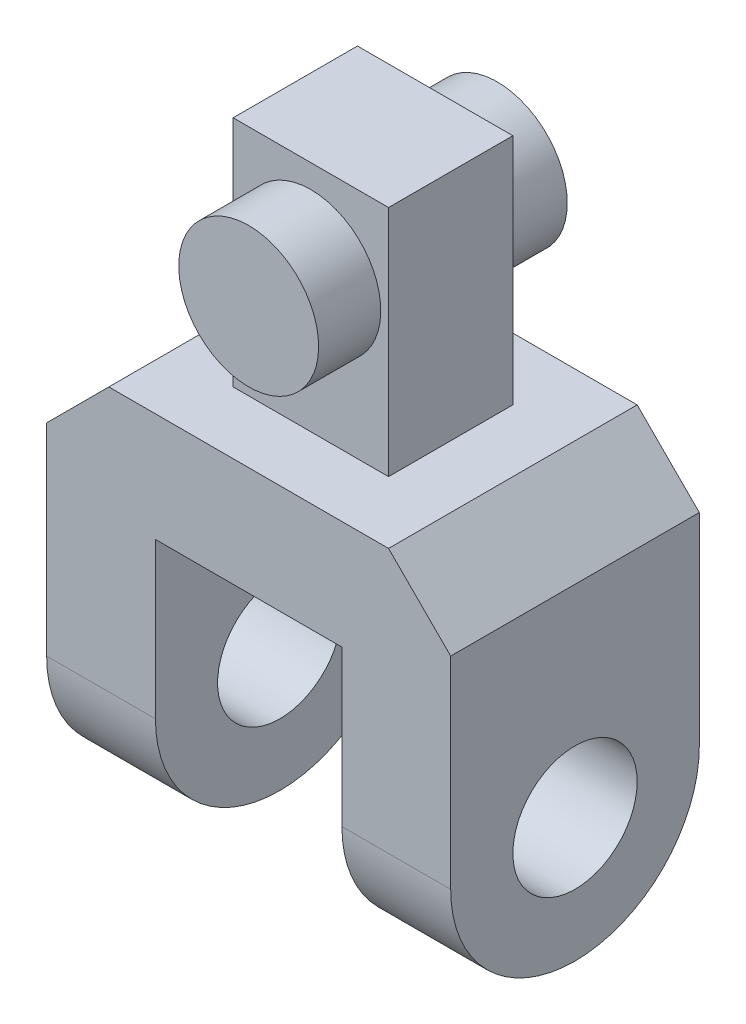
from build123d import *

# Parameters (mm, degrees)
BOSS_EXTRUDE1_START = 6
SKETCH1_R           = 4
BOSS_EXTRUDE1_DEPTH = 7
BOSS_EXTRUDE2_START = -6
SKETCH1_2_R         = 4
BOSS_EXTRUDE2_DEPTH = 7
SKETCH2_W           = 26
SKETCH2_H           = 16
BOSS_EXTRUDE3_DEPTH = 7
CHAMFER1_SIZE       = 4
SKETCH3_W           = 10
SKETCH3_H           = 8
BOSS_EXTRUDE4_DEPTH = 15
SKETCH5_R           = 4.5
BOSS_EXTRUDE5_DEPTH = 8


with BuildPart() as part:
    # Sketch1 → Boss-Extrude1 (new body)
    with BuildSketch(Plane(origin=(0, 0, 0), x_dir=(0, 0, -1), z_dir=(1, 0, 0)).offset(BOSS_EXTRUDE1_START)):
        with BuildLine():
            Line((8, 10), (-8, 10))
            Line((-8, 10), (-8, 0))
            ThreePointArc((-8, 0), (0, -8), (8, 0))
            Line((8, 0), (8, 10))
        make_face()
        Circle(SKETCH1_R, mode=Mode.SUBTRACT)
    extrude(amount=BOSS_EXTRUDE1_DEPTH)



with BuildPart() as body_2:
    # Sketch1_2 → Boss-Extrude2 (new body)
    with BuildSketch(Plane(origin=(0, 0, 0), x_dir=(0, 0, -1), z_dir=(1, 0, 0)).offset(BOSS_EXTRUDE2_START)):
        with BuildLine():
            Line((8, 10), (-8, 10))
            Line((-8, 10), (-8, 0))
            ThreePointArc((-8, 0), (0, -8), (8, 0))
            Line((8, 0), (8, 10))
        make_face()
        Circle(SKETCH1_2_R, mode=Mode.SUBTRACT)
    extrude(amount=-BOSS_EXTRUDE2_DEPTH)


with BuildPart() as part_1:
    add(part.part)

    add(body_2.part)  # Boss-Extrude3 merges body 2
    # Sketch2 → Boss-Extrude3 (add)
    with BuildSketch(Plane(origin=(0, 10, 0), x_dir=(1, 0, 0), z_dir=(0, 1, 0))):
        Rectangle(SKETCH2_W, SKETCH2_H)
    extrude(amount=BOSS_EXTRUDE3_DEPTH)

    # Chamfer1
    chamfer1_edges = [part_1.edges().sort_by_distance(p)[0] for p in [
        (13, 17, 0),
        (-13, 17, 0),
    ]]
    chamfer(chamfer1_edges, length=CHAMFER1_SIZE)

    # Sketch3 → Boss-Extrude4 (add)
    with BuildSketch(Plane(origin=(0, 17, 0), x_dir=(1, 0, 0), z_dir=(0, 1, 0))):
        Rectangle(SKETCH3_W, SKETCH3_H)
    extrude(amount=BOSS_EXTRUDE4_DEPTH)

    # Sketch5 → Boss-Extrude5 (add, symmetric)
    with BuildSketch(Plane.XY):
        with Locations((0, 26)):
            Circle(SKETCH5_R)
    extrude(amount=BOSS_EXTRUDE5_DEPTH, both=True)


solid = part_1.part
